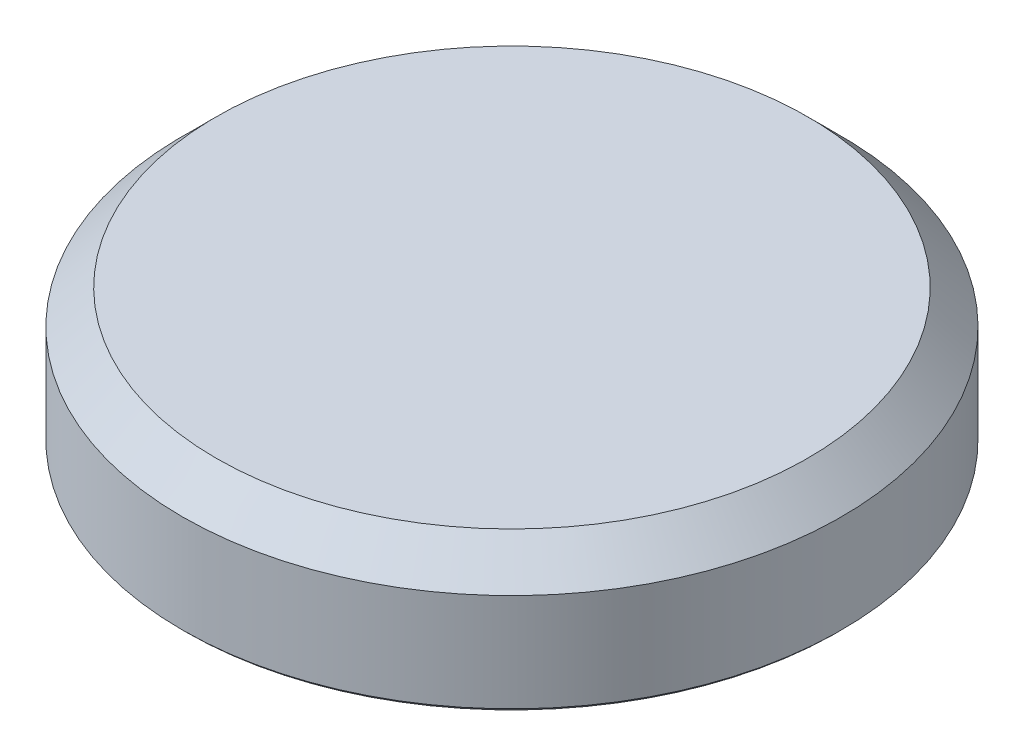
from build123d import *

# Parameters (mm, degrees)
SKETCH2_R                       = 24.765
BOSS_EXTRUDE1_DEPTH             = 10.16
CHAMFER1_SIZE                   = 2.54
CHAMFER2_SIZE                   = 0.254
B_0_238_DIAMETER_HOLE1_D        = 6.0452
B_0_238_DIAMETER_HOLE1_DEPTH    = 3.81
B_0_238_DIAMETER_HOLE1_TIP      = 1.816161307
F_1_4_0_25_DIAMETER_HOLE1_D     = 6.35
F_1_4_0_25_DIAMETER_HOLE1_DEPTH = 7.62
F_1_4_0_25_DIAMETER_HOLE1_TIP   = 1.907732465


with BuildPart() as part:
    # Sketch2 → Boss-Extrude1 (new body)
    with BuildSketch(Plane(origin=(0, 0, 0), x_dir=(1, 0, 0), z_dir=(0, 1, 0))):
        Circle(SKETCH2_R)
    extrude(amount=BOSS_EXTRUDE1_DEPTH)

    # Chamfer1
    chamfer1_edges = [part.edges().sort_by_distance(p)[0] for p in [
        (-24.765, 10.16, 0),
    ]]
    chamfer(chamfer1_edges, length=CHAMFER1_SIZE)

    # Chamfer2
    chamfer2_edges = [part.edges().sort_by_distance(p)[0] for p in [
        (-24.765, 0, 0),
    ]]
    chamfer(chamfer2_edges, length=CHAMFER2_SIZE)

    # B (0.238) Diameter Hole1
    with Locations(Plane(origin=(0, 0, 0), x_dir=(-1, 0, 0), z_dir=(0, -1, 0))):
        with Locations((-4.939140867, 4.939140867), (4.939140867, 4.939140867), (4.939140867, -4.939140867), (-4.939140867, -4.939140867)):
            Hole(B_0_238_DIAMETER_HOLE1_D / 2, depth=B_0_238_DIAMETER_HOLE1_DEPTH)
            with Locations((0, 0, -(B_0_238_DIAMETER_HOLE1_DEPTH + B_0_238_DIAMETER_HOLE1_TIP / 2))):  # 118° drill point
                Cone(0, B_0_238_DIAMETER_HOLE1_D / 2, B_0_238_DIAMETER_HOLE1_TIP, mode=Mode.SUBTRACT)

    # 1/4 (0.25) Diameter Hole1
    with Locations(Plane(origin=(0, 0, 0), x_dir=(-1, 0, 0), z_dir=(0, -1, 0))):
        with Locations((0, 0)):
            Hole(F_1_4_0_25_DIAMETER_HOLE1_D / 2, depth=F_1_4_0_25_DIAMETER_HOLE1_DEPTH)
            with Locations((0, 0, -(F_1_4_0_25_DIAMETER_HOLE1_DEPTH + F_1_4_0_25_DIAMETER_HOLE1_TIP / 2))):  # 118° drill point
                Cone(0, F_1_4_0_25_DIAMETER_HOLE1_D / 2, F_1_4_0_25_DIAMETER_HOLE1_TIP, mode=Mode.SUBTRACT)


solid = part.part
